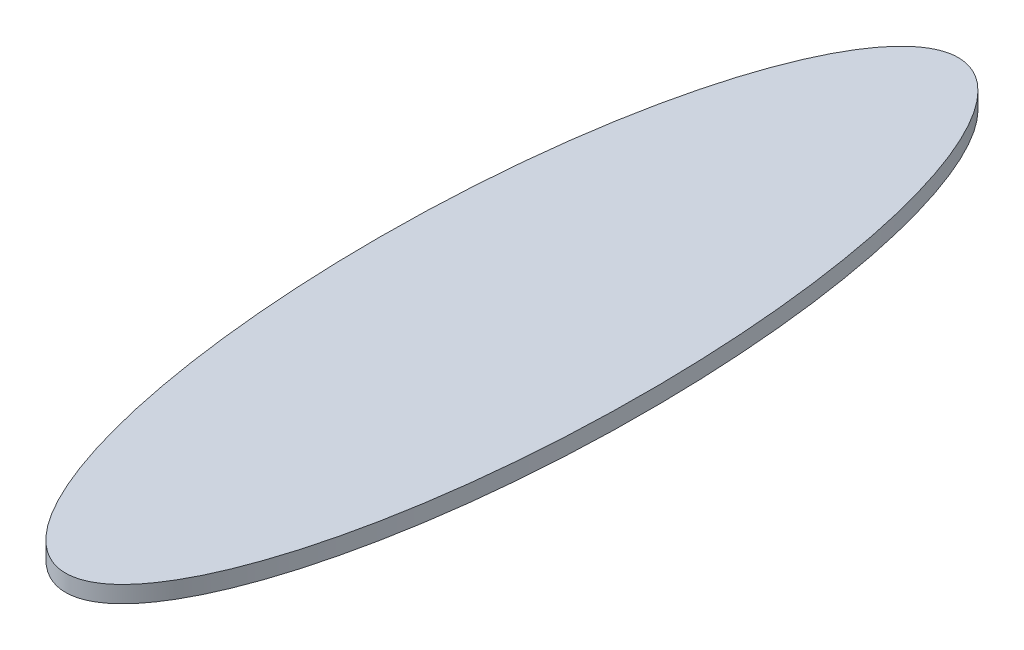
from build123d import *

# Parameters (mm, degrees)
SKETCH1_RX          = 127
SKETCH1_RY          = 38.1
BOSS_EXTRUDE1_DEPTH = 4.7625


with BuildPart() as part:
    # Sketch1 → Boss-Extrude1 (new body)
    with BuildSketch(Plane(origin=(0, 0, 0), x_dir=(1, 0, 0), z_dir=(0, 1, 0))):
        with Locations(Location((0, 0), (0, 0, 90))):
            Ellipse(SKETCH1_RX, SKETCH1_RY)
    extrude(amount=BOSS_EXTRUDE1_DEPTH)


solid = part.part
